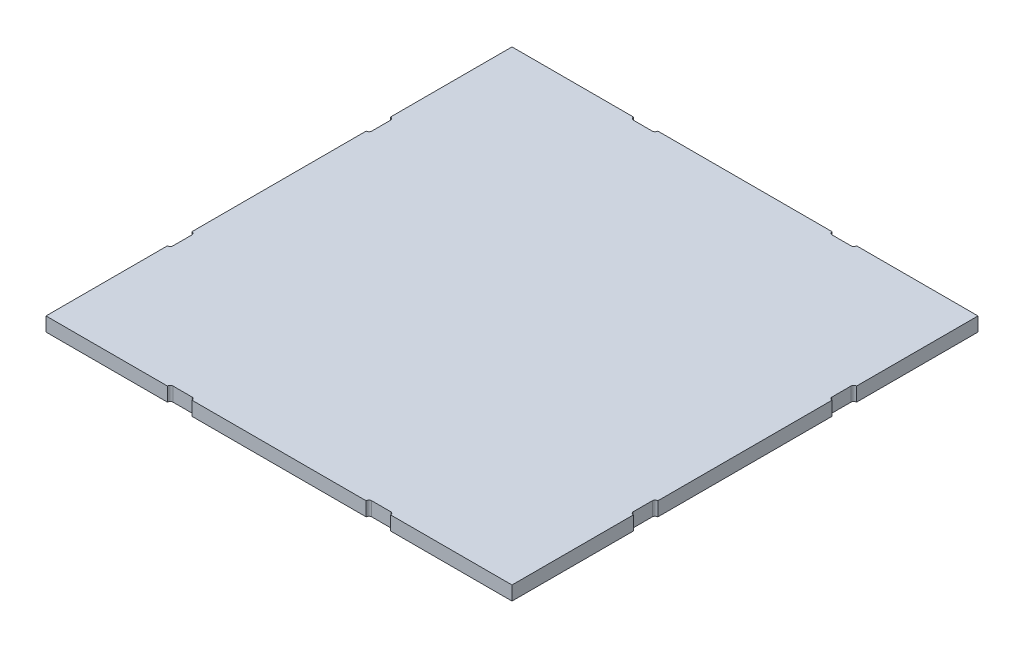
from build123d import *

# Parameters (mm, degrees)
SKETCH1_W           = 333
SKETCH1_H           = 333
BOSS_EXTRUDE1_DEPTH = 10
CUT_EXTRUDE1_DEPTH  = 11


with BuildPart() as part:
    # Sketch1 → Boss-Extrude1 (new body)
    with BuildSketch(Plane(origin=(0, 0, 0), x_dir=(1, 0, 0), z_dir=(0, 1, 0))):
        Rectangle(SKETCH1_W, SKETCH1_H)
    extrude(amount=BOSS_EXTRUDE1_DEPTH)

    # Sketch2 → Cut-Extrude1 (cut, through all)
    with BuildSketch(Plane(origin=(0, 10, 0), x_dir=(1, 0, 0), z_dir=(0, 1, 0))):
        with BuildLine():
            Line((-77.75, -164.5), (-64.25, -164.5))
            ThreePointArc((-64.25, -164.5), (-62.835786438, -165.085786438), (-62.25, -166.5))
            Line((-62.25, -166.5), (-62.25, -168.5))
            Line((-62.25, -168.5), (-79.75, -168.5))
            Line((-79.75, -168.5), (-79.75, -166.5))
            ThreePointArc((-79.75, -166.5), (-79.164213562, -165.085786438), (-77.75, -164.5))
        make_face()
        with BuildLine():
            Line((166.5, -62.25), (168.5, -62.25))
            Line((168.5, -62.25), (168.5, -79.75))
            Line((168.5, -79.75), (166.5, -79.75))
            ThreePointArc((166.5, -79.75), (165.085786438, -79.164213562), (164.5, -77.75))
            Line((164.5, -77.75), (164.5, -64.25))
            ThreePointArc((164.5, -64.25), (165.085786438, -62.835786438), (166.5, -62.25))
        make_face()
        with BuildLine():
            Line((62.25, -166.5), (62.25, -168.5))
            Line((62.25, -168.5), (79.75, -168.5))
            Line((79.75, -168.5), (79.75, -166.5))
            ThreePointArc((79.75, -166.5), (79.164213562, -165.085786438), (77.75, -164.5))
            Line((77.75, -164.5), (64.25, -164.5))
            ThreePointArc((64.25, -164.5), (62.835786438, -165.085786438), (62.25, -166.5))
        make_face()
        with BuildLine():
            Line((168.5, 62.25), (168.5, 79.75))
            Line((168.5, 79.75), (166.5, 79.75))
            ThreePointArc((166.5, 79.75), (165.085786438, 79.164213562), (164.5, 77.75))
            Line((164.5, 77.75), (164.5, 64.25))
            ThreePointArc((164.5, 64.25), (165.085786438, 62.835786438), (166.5, 62.25))
            Line((166.5, 62.25), (168.5, 62.25))
        make_face()
        with BuildLine():
            Line((-166.5, 62.25), (-168.5, 62.25))
            Line((-168.5, 62.25), (-168.5, 79.75))
            Line((-168.5, 79.75), (-166.5, 79.75))
            ThreePointArc((-166.5, 79.75), (-165.085786438, 79.164213562), (-164.5, 77.75))
            Line((-164.5, 77.75), (-164.5, 64.25))
            ThreePointArc((-164.5, 64.25), (-165.085786438, 62.835786438), (-166.5, 62.25))
        make_face()
        with BuildLine():
            Line((-168.5, -62.25), (-168.5, -79.75))
            Line((-168.5, -79.75), (-166.5, -79.75))
            ThreePointArc((-166.5, -79.75), (-165.085786438, -79.164213562), (-164.5, -77.75))
            Line((-164.5, -77.75), (-164.5, -64.25))
            ThreePointArc((-164.5, -64.25), (-165.085786438, -62.835786438), (-166.5, -62.25))
            Line((-166.5, -62.25), (-168.5, -62.25))
        make_face()
        with BuildLine():
            Line((77.75, 164.5), (64.25, 164.5))
            ThreePointArc((64.25, 164.5), (62.835786438, 165.085786438), (62.25, 166.5))
            Line((62.25, 166.5), (62.25, 168.5))
            Line((62.25, 168.5), (79.75, 168.5))
            Line((79.75, 168.5), (79.75, 166.5))
            ThreePointArc((79.75, 166.5), (79.164213562, 165.085786438), (77.75, 164.5))
        make_face()
        with BuildLine():
            Line((-62.25, 166.5), (-62.25, 168.5))
            Line((-62.25, 168.5), (-79.75, 168.5))
            Line((-79.75, 168.5), (-79.75, 166.5))
            ThreePointArc((-79.75, 166.5), (-79.164213562, 165.085786438), (-77.75, 164.5))
            Line((-77.75, 164.5), (-64.25, 164.5))
            ThreePointArc((-64.25, 164.5), (-62.835786438, 165.085786438), (-62.25, 166.5))
        make_face()
    extrude(amount=-CUT_EXTRUDE1_DEPTH, mode=Mode.SUBTRACT)


solid = part.part
